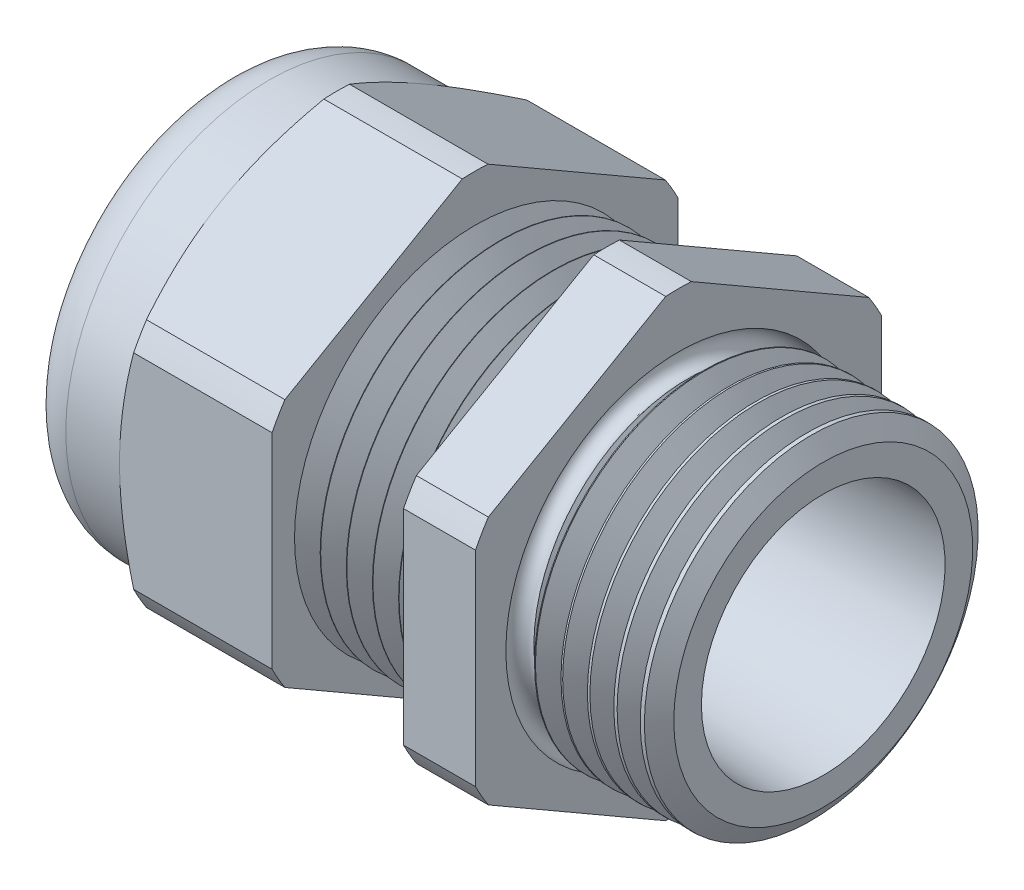
from build123d import *

# Parameters (mm, degrees)
SKETCH2_OUTSIDE_W  = 36.338
SKETCH2_OUTSIDE_H  = 36.338
CUT_EXTRUDE1_DEPTH = 19.3675
SKETCH14_W         = 5.5245
SKETCH14_H         = 1.778
CHAMFER1_SIZE      = 0.326149358
CHAMFER1_SIZE2     = 0.3175
SKETCH3_OUTSIDE_W  = 131.256
SKETCH3_OUTSIDE_H  = 133.908
SKETCH3_OUTSIDE_R  = 11.049
CUT_EXTRUDE2_DEPTH = 28.2415
CUT_EXTRUDE2_DRAFT = -60
SKETCH9_W          = 5.0165
SKETCH9_H          = 1.91135
FILLET1_R          = 2.59588
LPATTERN1_COUNT    = 6
LPATTERN1_PITCH    = 1.4224
LPATTERN2_COUNT    = 6
LPATTERN2_PITCH    = 1.4224
SKETCH15_R         = 0.635
FILLET3_R          = 0.254


with BuildPart() as part:
    # Sketch1 → Revolve1 (revolve)
    with BuildSketch(Plane.XY, mode=Mode.PRIVATE) as revolve1_sk:
        Polygon((-11.070166667, 9.82726), (-11.070166667, 12.37488), (-19.3675, 12.37488), (-19.3675, 9.271), (-24.892, 9.271), (-24.892, 7.88035), (-19.3675, 7.88035), (-19.3675, 5.969), (-11.070166667, 5.969), (7.874, 6.630544877), (7.874, 9.064812054), (0, 9.271), (0, 12.37488), (-3.917412935, 12.37488), (-3.917412935, 9.82726), align=None)
    revolve(revolve1_sk.sketch.rotate(Axis((-18.386021217, 0, 0), (1, 0, 0)), 90), axis=Axis((-18.386021217, 0, 0), (1, 0, 0)))  # turned: the seam where the file's is

    # Sketch2 outside → Cut-Extrude1 (cut)
    with BuildSketch(Plane(origin=(0, 0, 0), x_dir=(0, 0, -1), z_dir=(1, 0, 0))):
        Rectangle(SKETCH2_OUTSIDE_W, SKETCH2_OUTSIDE_H)
        with BuildLine():
            Line((11.049, -5.572903553), (11.049, 5.572903553))
            ThreePointArc((11.049, 5.572903553), (10.716960449, 6.18744), (10.35077605, 6.78226291))
            Line((10.35077605, 6.78226291), (0.69822395, 12.355166463))
            ThreePointArc((0.69822395, 12.355166463), (0, 12.37488), (-0.69822395, 12.355166463))
            Line((-0.69822395, 12.355166463), (-10.35077605, 6.78226291))
            ThreePointArc((-10.35077605, 6.78226291), (-10.716960449, 6.18744), (-11.049, 5.572903553))
            Line((-11.049, 5.572903553), (-11.049, -5.572903553))
            ThreePointArc((-11.049, -5.572903553), (-10.716960449, -6.18744), (-10.35077605, -6.78226291))
            Line((-10.35077605, -6.78226291), (-0.69822395, -12.355166463))
            ThreePointArc((-0.69822395, -12.355166463), (0, -12.37488), (0.69822395, -12.355166463))
            Line((0.69822395, -12.355166463), (10.35077605, -6.78226291))
            ThreePointArc((10.35077605, -6.78226291), (10.716960449, -6.18744), (11.049, -5.572903553))
        make_face(mode=Mode.SUBTRACT)
    extrude(amount=-CUT_EXTRUDE1_DEPTH, mode=Mode.SUBTRACT)

    # Sketch14 → Revolve4 (revolve)
    with BuildSketch(Plane.XY, mode=Mode.PRIVATE) as revolve4_sk:
        with Locations((-22.12975, 10.16)):
            Rectangle(SKETCH14_W, SKETCH14_H)
    revolve(revolve4_sk.sketch.rotate(Axis((-18.386021217, 0, 0), (1, 0, 0)), 90), axis=Axis((-18.386021217, 0, 0), (1, 0, 0)))  # turned: the seam where the file's is

    # Chamfer1
    chamfer1_edges = [part.edges().sort_by_distance(p)[0] for p in [
        (7.874, 0, -9.064812054),
    ]]
    chamfer1_side = [part.faces().sort_by_distance(p)[0] for p in [
        (3.937, 0, -9.167906027),
    ]]
    chamfer(chamfer1_edges, length=CHAMFER1_SIZE, length2=CHAMFER1_SIZE2, reference=chamfer1_side[0])


with BuildPart() as cut_extrude2_tool:
    # Sketch3 outside → Cut-Extrude2 (with draft: the straight prism first)
    with BuildSketch(Plane.ZY.offset(19.3675)):
        Rectangle(SKETCH3_OUTSIDE_W, SKETCH3_OUTSIDE_H)
        Circle(SKETCH3_OUTSIDE_R, mode=Mode.SUBTRACT)
    extrude(amount=-CUT_EXTRUDE2_DEPTH)
    # Cut-Extrude2: the draft: its side faces are tilted about the plane it starts from
    cut_extrude2_sides = [cut_extrude2_tool.faces().sort_by_distance(p)[0] for p in [
        (-5.24675, -66.954, 0),
        (-5.24675, 0, 65.628),
        (-5.24675, 66.954, 0),
        (-5.24675, 0, -65.628),
        (-5.24675, 0, -11.049),
    ]]
    draft(cut_extrude2_sides, Plane.ZY.offset(19.3675), CUT_EXTRUDE2_DRAFT)


with BuildPart() as part_1:
    add(part.part)

    # Cut-Extrude2: cut by cut_extrude2_tool
    add(cut_extrude2_tool.part, mode=Mode.SUBTRACT)

    # Fillet1
    fillet1_edges = [part_1.edges().sort_by_distance(p)[0] for p in [
        (-24.892, 0, -11.049),
    ]]
    fillet(fillet1_edges, radius=FILLET1_R)

    # Sketch10 → Cut-Revolve1 (revolve, cut)
    with BuildSketch(Plane.XY, mode=Mode.PRIVATE) as cut_revolve1_sk:
        Polygon((-11.070166667, 9.82726), (-10.371666992, 8.617423075), (-9.673167318, 9.82726), align=None)
    cut_revolve1 = revolve(cut_revolve1_sk.sketch.rotate(Axis((15.58962545, 0, 0), (-1, 0, 0)), 90), axis=Axis((15.58962545, 0, 0), (-1, 0, 0)), mode=Mode.SUBTRACT)  # turned: the seam where the file's is

    # LPattern1: Cut-Revolve1 ×6
    with Locations(*[(i * LPATTERN1_PITCH, 0, 0) for i in range(1, LPATTERN1_COUNT)]):
        add(cut_revolve1, mode=Mode.SUBTRACT)

    # Sketch13 → Cut-Revolve2 (revolve, cut)
    with BuildSketch(Plane.XY, mode=Mode.PRIVATE) as cut_revolve2_sk:
        Polygon((0, 9.271), (1.397797721, 9.234397379), (0.709465127, 8.042170354), align=None)
    cut_revolve2 = revolve(cut_revolve2_sk.sketch.rotate(Axis((-18.386021217, 0, 0), (1, 0, 0)), 270), axis=Axis((-18.386021217, 0, 0), (1, 0, 0)), mode=Mode.SUBTRACT)  # turned: the seam where the file's is

    # LPattern2: Cut-Revolve2 ×6
    with Locations(*[(i * LPATTERN2_PITCH, 0, 0) for i in range(1, LPATTERN2_COUNT)]):
        add(cut_revolve2, mode=Mode.SUBTRACT)

    # Sketch15 → Cut-Revolve4 (revolve, cut)
    with BuildSketch(Plane.XY, mode=Mode.PRIVATE) as cut_revolve4_sk:
        with Locations((0, -8.763)):
            Circle(SKETCH15_R)
    revolve(cut_revolve4_sk.sketch.rotate(Axis((10.155027747, 0, 0), (-1, 0, 0)), 270), axis=Axis((10.155027747, 0, 0), (-1, 0, 0)), mode=Mode.SUBTRACT)  # turned: the seam where the file's is


with BuildPart() as body_2:
    # Sketch9 → Revolve3 (revolve)
    with BuildSketch(Plane.XY, mode=Mode.PRIVATE) as revolve3_sk:
        with Locations((-21.87575, 6.924675)):
            Rectangle(SKETCH9_W, SKETCH9_H)
    revolve(revolve3_sk.sketch.rotate(Axis((8.695207459, 0, 0), (-1, 0, 0)), 270), axis=Axis((8.695207459, 0, 0), (-1, 0, 0)))  # turned: the seam where the file's is

    # Fillet3
    fillet3_edges = [body_2.edges().sort_by_distance(p)[0] for p in [
        (-24.384, 0, -7.88035),
    ]]
    fillet(fillet3_edges, radius=FILLET3_R)


solid = Compound([part_1.part, body_2.part])
